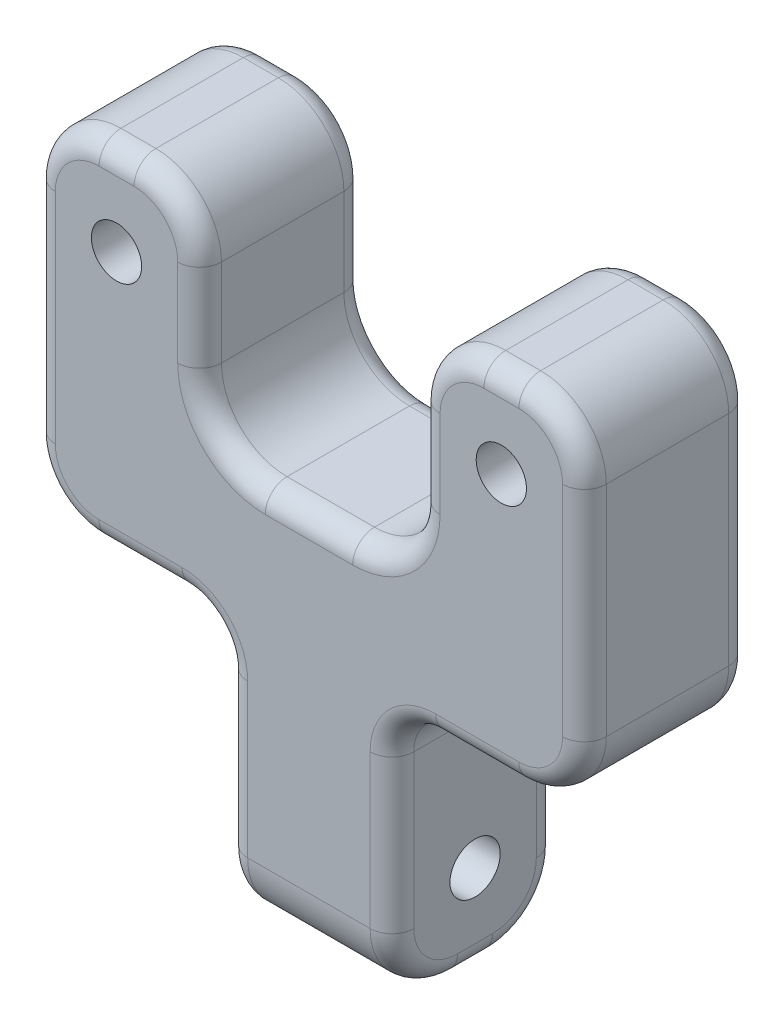
from build123d import *

# Parameters (mm, degrees)
BOSS_EXTRUDE1_DEPTH      = 3.8
BOSS_EXTRUDE1_DEPTH_BACK = 3.8
SKETCH2_R                = 1.15
CUT_EXTRUDE1_DEPTH       = 7.6
SKETCH3_R                = 1.15
CUT_EXTRUDE2_DEPTH       = 7.6
FILLET1_R                = 3
FILLET2_R                = 3
FILLET3_R                = 2
FILLET4_R                = 1


with BuildPart() as part:
    # Sketch1 → Boss-Extrude1 (new, two sides: drawn at the far end of the back side and taken through both)
    with BuildSketch(Plane.XY.offset(-BOSS_EXTRUDE1_DEPTH_BACK)):
        Polygon((-12.6, 6), (-3.8, 6), (-3.8, -6), (3.8, -6), (3.8, 6), (12.6, 6), (12.6, 22), (5, 22), (5, 12), (-5, 12), (-5, 22), (-12.6, 22), align=None)
    extrude(amount=BOSS_EXTRUDE1_DEPTH + BOSS_EXTRUDE1_DEPTH_BACK)

    # Sketch2 → Cut-Extrude1 (cut)
    with BuildSketch(Plane(origin=(3.8, 0, 0), x_dir=(0, 0, -1), z_dir=(1, 0, 0))):
        with Locations((0, -2)):
            Circle(SKETCH2_R)
    extrude(amount=-CUT_EXTRUDE1_DEPTH, mode=Mode.SUBTRACT)

    # Sketch3 → Cut-Extrude2 (cut)
    with BuildSketch(Plane.XY.offset(3.8)):
        with Locations((-8.8, 18)):
            Circle(SKETCH3_R)
        with Locations((8.8, 18)):
            Circle(SKETCH3_R)
    extrude(amount=-CUT_EXTRUDE2_DEPTH, mode=Mode.SUBTRACT)

    # Fillet1
    fillet1_edges = [part.edges().sort_by_distance(p)[0] for p in [
        (0, -6, -3.8),
        (0, -6, 3.8),
        (12.6, 22, 0),
        (5, 22, 0),
        (-5, 22, 0),
        (-12.6, 22, 0),
    ]]
    fillet(fillet1_edges, radius=FILLET1_R)

    # Fillet2
    fillet2_edges = [part.edges().sort_by_distance(p)[0] for p in [
        (12.6, 6, 0),
        (-12.6, 6, 0),
        (5, 12, 0),
        (-5, 12, 0),
    ]]
    fillet(fillet2_edges, radius=FILLET2_R)

    # Fillet3
    fillet3_edges = [part.edges().sort_by_distance(p)[0] for p in [
        (3.8, 6, 0),
        (-3.8, 6, 0),
    ]]
    fillet(fillet3_edges, radius=FILLET3_R)

    # Fillet4
    fillet4_edges = [part.edges().sort_by_distance(p)[0] for p in [
        (-11.721320344, 6.878679656, 3.8),
        (-7.7, 6, 3.8),
        (-4.385786438, 5.414213562, 3.8),
        (-3.8, 0.5, 3.8),
        (-3.8, -5.121320344, 2.921320344),
        (-3.8, -6, 0),
        (-3.8, -5.121320344, -2.921320344),
        (-3.8, 0.5, -3.8),
        (-4.385786438, 5.414213562, -3.8),
        (-7.7, 6, -3.8),
        (-11.721320344, 6.878679656, -3.8),
        (-12.6, 14, -3.8),
        (-11.721320344, 21.121320344, -3.8),
        (-8.8, 22, -3.8),
        (-5.878679656, 21.121320344, -3.8),
        (-5, 17, -3.8),
        (-4.121320344, 12.878679656, -3.8),
        (0, 12, -3.8),
        (4.121320344, 12.878679656, -3.8),
        (5, 17, -3.8),
        (5.878679656, 21.121320344, -3.8),
        (8.8, 22, -3.8),
        (11.721320344, 21.121320344, -3.8),
        (12.6, 14, -3.8),
        (11.721320344, 6.878679656, -3.8),
        (7.7, 6, -3.8),
        (4.385786438, 5.414213562, -3.8),
        (3.8, 0.5, -3.8),
        (3.8, -5.121320344, -2.921320344),
        (3.8, -6, 0),
        (3.8, -5.121320344, 2.921320344),
        (3.8, 0.5, 3.8),
        (4.385786438, 5.414213562, 3.8),
        (7.7, 6, 3.8),
        (11.721320344, 6.878679656, 3.8),
        (12.6, 14, 3.8),
        (11.721320344, 21.121320344, 3.8),
        (8.8, 22, 3.8),
        (5.878679656, 21.121320344, 3.8),
        (5, 17, 3.8),
        (4.121320344, 12.878679656, 3.8),
        (0, 12, 3.8),
        (-4.121320344, 12.878679656, 3.8),
        (-5, 17, 3.8),
        (-5.878679656, 21.121320344, 3.8),
        (-8.8, 22, 3.8),
        (-11.721320344, 21.121320344, 3.8),
        (-12.6, 14, 3.8),
    ]]
    fillet(fillet4_edges, radius=FILLET4_R)


solid = part.part
